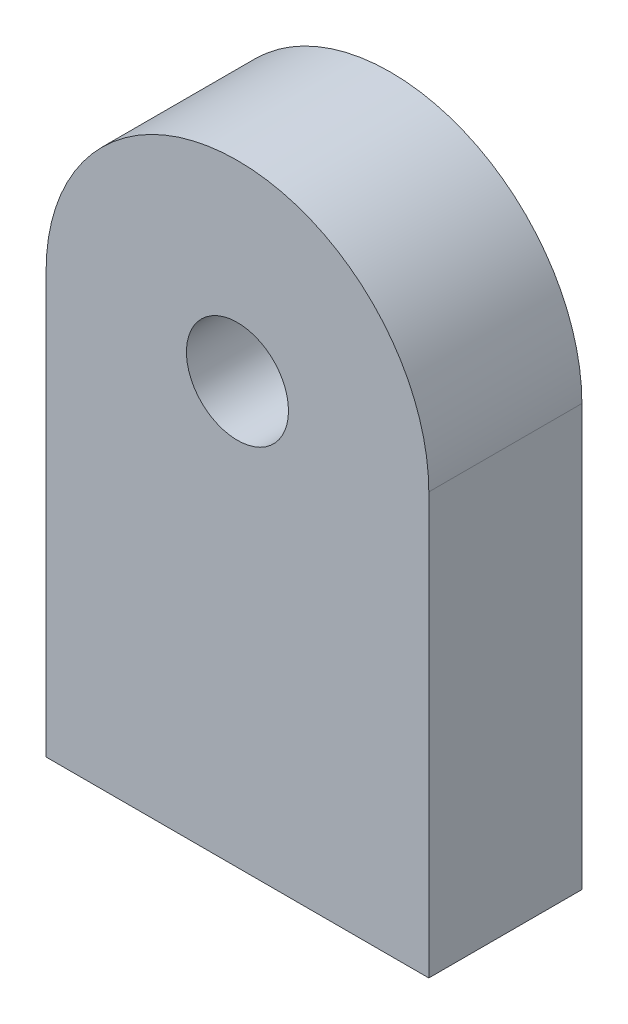
from build123d import *

# Parameters (mm, degrees)
SKETCH2_R           = 15
SKETCH2_R_2         = 11
BOSS_EXTRUDE1_DEPTH = 4
SKETCH3_R           = 15
SKETCH3_R_2         = 4
BOSS_EXTRUDE2_DEPTH = 8
BOSS_EXTRUDE5_DEPTH = 12
SKETCH7_R           = 3
CUT_EXTRUDE1_DEPTH  = 14


with BuildPart() as part:
    # Sketch2 → Boss-Extrude1 (new body)
    with BuildSketch(Plane.XY):
        Circle(SKETCH2_R)
        Circle(SKETCH2_R_2, mode=Mode.SUBTRACT)
    extrude(amount=BOSS_EXTRUDE1_DEPTH)

    # Sketch3 → Boss-Extrude2 (add)
    with BuildSketch(Plane.XY.offset(4)):
        Circle(SKETCH3_R)
        Circle(SKETCH3_R_2, mode=Mode.SUBTRACT)
    extrude(amount=BOSS_EXTRUDE2_DEPTH)

    # Sketch6 → Boss-Extrude5 (add)
    with BuildSketch(Plane.XY.offset(12)):
        with BuildLine():
            Line((-15, 0), (-15, -33))
            Line((-15, -33), (15, -33))
            Line((15, -33), (15, 0))
            ThreePointArc((15, 0), (0, -15), (-15, 0))
        make_face()
    extrude(amount=-BOSS_EXTRUDE5_DEPTH)

    # Sketch7 → Cut-Extrude1 (cut)
    with BuildSketch(Plane.XZ.offset(33)):
        with Locations((7, 6)):
            Circle(SKETCH7_R)
        with Locations((-7, 6)):
            Circle(SKETCH7_R)
    extrude(amount=-CUT_EXTRUDE1_DEPTH, mode=Mode.SUBTRACT)


solid = part.part
